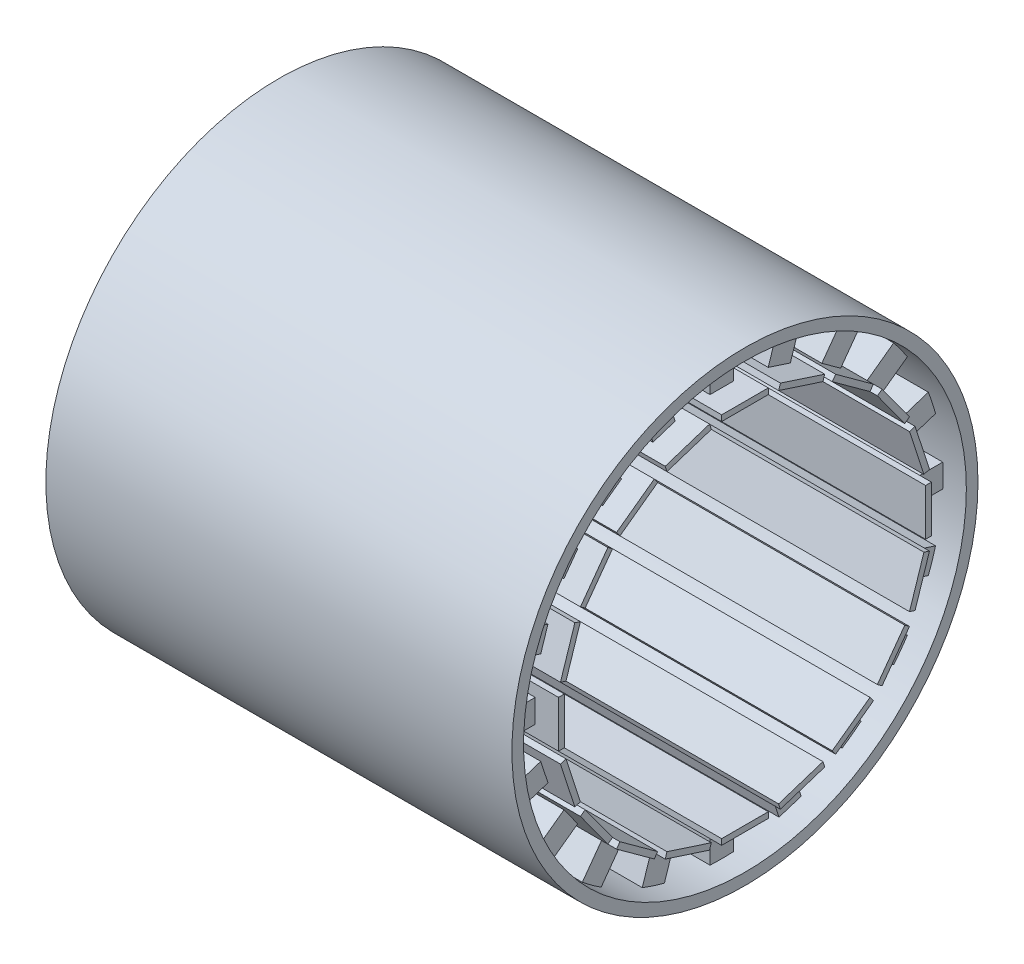
from build123d import *

# Parameters (mm, degrees)
SKETCH2_R           = 50.8
SKETCH2_R_2         = 48.26
BOSS_EXTRUDE1_DEPTH = 50.8
SKETCH3_W           = 5.08
SKETCH3_H           = 7.62
BOSS_EXTRUDE2_DEPTH = 45.72
SKETCH4_W           = 101.6
SKETCH4_H           = 10.16
BOSS_EXTRUDE3_DEPTH = 1.27
CIRPATTERN1_COUNT   = 20


with BuildPart() as part:
    # Sketch2 → Boss-Extrude1 (new body, symmetric)
    with BuildSketch(Plane(origin=(0, 0, 0), x_dir=(0, 0, -1), z_dir=(1, 0, 0))):
        Circle(SKETCH2_R)
        Circle(SKETCH2_R_2, mode=Mode.SUBTRACT)
    extrude(amount=BOSS_EXTRUDE1_DEPTH, both=True)

    # Sketch3 → Boss-Extrude2 (add, symmetric)
    with BuildSketch(Plane(origin=(0, 0, 0), x_dir=(0, 0, -1), z_dir=(1, 0, 0))):
        with Locations((0, -44.45)):
            Rectangle(SKETCH3_W, SKETCH3_H)
    boss_extrude2 = extrude(amount=BOSS_EXTRUDE2_DEPTH, both=True)

    # Sketch4 → Boss-Extrude3 (add)
    with BuildSketch(Plane(origin=(0, -40.64, 0), x_dir=(1, 0, 0), z_dir=(0, 1, 0))):
        Rectangle(SKETCH4_W, SKETCH4_H)
    boss_extrude3 = extrude(amount=BOSS_EXTRUDE3_DEPTH)

    # CirPattern1: Boss-Extrude2, Boss-Extrude3 ×20 about axis
    cirpattern1_axis = Axis((0, 0, 0), (1, 0, 0))
    for i in range(1, CIRPATTERN1_COUNT):
        add(boss_extrude2.rotate(cirpattern1_axis, i * 360 / CIRPATTERN1_COUNT))
        add(boss_extrude3.rotate(cirpattern1_axis, i * 360 / CIRPATTERN1_COUNT))


solid = part.part
